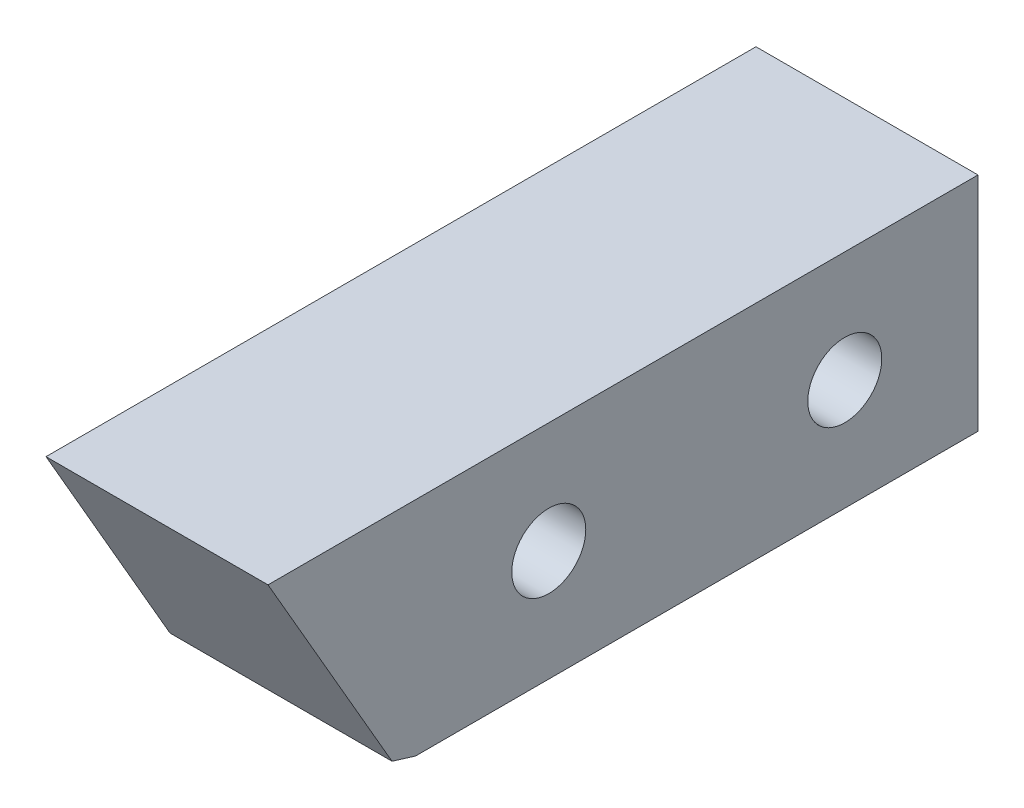
from build123d import *

# Parameters (mm, degrees)
SKETCH1_W      = 9.525
SKETCH1_H      = 24.13
EXTRUDE1_DEPTH = 9.525
SKETCH2_R      = 1.5875
EXTRUDE2_DEPTH = 10.525
EXTRUDE3_DEPTH = 9.525


with BuildPart() as part:
    # Sketch1 → Extrude1 (new body)
    with BuildSketch(Plane(origin=(0, 0, 0), x_dir=(1, 0, 0), z_dir=(0, 1, 0))):
        Rectangle(SKETCH1_W, SKETCH1_H)
    extrude(amount=EXTRUDE1_DEPTH)

    # Sketch2 → Extrude2 (cut, through all)
    with BuildSketch(Plane(origin=(4.7625, 0, 0), x_dir=(0, 0, -1), z_dir=(1, 0, 0))):
        with Locations((-6.35, 4.7625)):
            Circle(SKETCH2_R)
        with Locations(Location((6.35, 4.7625, 0), (0, 0, 180))):  # turned: the seam where the file's is
            Circle(SKETCH2_R)
    extrude(amount=-EXTRUDE2_DEPTH, mode=Mode.SUBTRACT)

    # Sketch3 → Extrude3 (add, through all)
    with BuildSketch(Plane(origin=(4.7625, 0, 0), x_dir=(0, 0, -1), z_dir=(1, 0, 0))):
        Polygon((-12.065, 9.525), (-18.394320409, 9.525), (-13.074387176, 0.310605347), (-12.065, 0), align=None)
    extrude(amount=-EXTRUDE3_DEPTH)


solid = part.part
